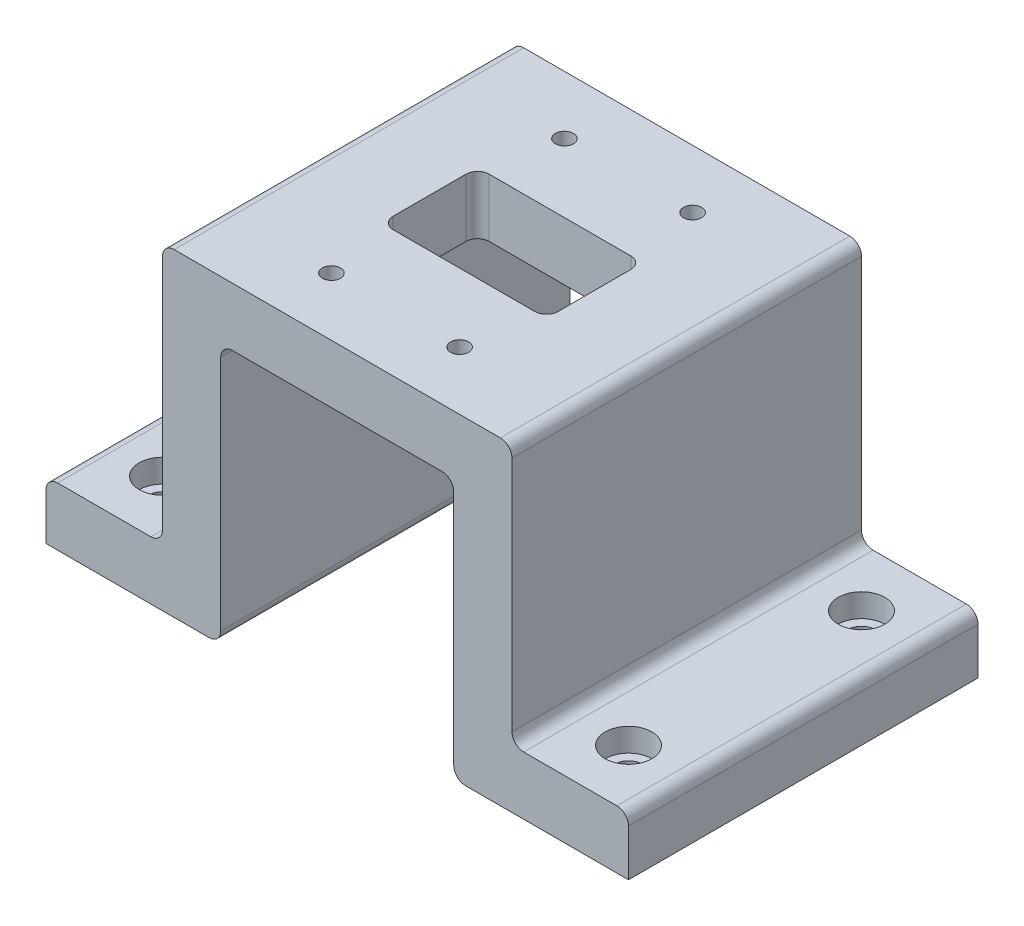
from build123d import *

# Parameters (mm, degrees)
SKETCH2_W                        = 60
SKETCH2_H                        = 60
BOSS_EXTRUDE1_DEPTH              = 10
SKETCH7_W                        = 28.32
SKETCH7_H                        = 16.5
CUT_EXTRUDE2_DEPTH               = 44.588989435
FILLET2_R                        = 2
CBORE_FOR_M2_5_SHCS2_D           = 3.1
CBORE_FOR_M2_5_SHCS2_CBORE_D     = 5.5
CBORE_FOR_M2_5_SHCS2_CBORE_DEPTH = 2.5
MOVE_FACE1_BY                    = 3.5
MOVE_FACE1_2_BY                  = 3.5
MOVE_FACE1_3_BY                  = 3.5
MOVE_FACE1_4_BY                  = 3.5
SKETCH11_W                       = 10
SKETCH11_H                       = 44.7
BOSS_EXTRUDE2_DEPTH              = 60
SKETCH12_W                       = 20
SKETCH12_H                       = 60
BOSS_EXTRUDE3_DEPTH              = 10
CBORE_FOR_M4_SHCS1_D             = 4.8
CBORE_FOR_M4_SHCS1_CBORE_D       = 8
CBORE_FOR_M4_SHCS1_CBORE_DEPTH   = 4
FILLET5_R                        = 2


with BuildPart() as part:
    # Sketch2 → Boss-Extrude1 (new body)
    with BuildSketch(Plane(origin=(0, 0, 0), x_dir=(1, 0, 0), z_dir=(0, 1, 0))):
        Rectangle(SKETCH2_W, SKETCH2_H)
    extrude(amount=BOSS_EXTRUDE1_DEPTH)

    # Sketch7 → Cut-Extrude2 (cut, through all)
    with BuildSketch(Plane(origin=(0, 10, 0), x_dir=(1, 0, 0), z_dir=(0, 1, 0))):
        Rectangle(SKETCH7_W, SKETCH7_H)
    extrude(amount=-CUT_EXTRUDE2_DEPTH, mode=Mode.SUBTRACT)

    # Fillet2
    fillet2_edges = [part.edges().sort_by_distance(p)[0] for p in [
        (-14.16, 5, 8.25),
        (-14.16, 5, -8.25),
        (14.16, 5, -8.25),
        (14.16, 5, 8.25),
    ]]
    fillet(fillet2_edges, radius=FILLET2_R)

    # CBORE for M2.5 SHCS2 (through all)
    with Locations(Plane(origin=(0, 0, 0), x_dir=(-1, 0, 0), z_dir=(0, -1, 0))):
        with Locations((11, -20), (-11, -20), (11, 20), (-11, 20)):
            CounterBoreHole(CBORE_FOR_M2_5_SHCS2_D / 2, CBORE_FOR_M2_5_SHCS2_CBORE_D / 2, CBORE_FOR_M2_5_SHCS2_CBORE_DEPTH)

    # Move Face1: a face moved inward by 3.5
    extrude(part.faces().sort_by_distance((11, 2.5, -17.8))[0], amount=MOVE_FACE1_BY, dir=(0, 1, 0), mode=Mode.SUBTRACT)

    # Move Face1 2: a face moved inward by 3.5
    extrude(part.faces().sort_by_distance((-11, 2.5, -17.8))[0], amount=MOVE_FACE1_2_BY, dir=(0, 1, 0), mode=Mode.SUBTRACT)

    # Move Face1 3: a face moved inward by 3.5
    extrude(part.faces().sort_by_distance((11, 2.5, 22.2))[0], amount=MOVE_FACE1_3_BY, dir=(0, 1, 0), mode=Mode.SUBTRACT)

    # Move Face1 4: a face moved inward by 3.5
    extrude(part.faces().sort_by_distance((-11, 2.5, 22.2))[0], amount=MOVE_FACE1_4_BY, dir=(0, 1, 0), mode=Mode.SUBTRACT)

    # Sketch11 → Boss-Extrude2 (add)
    with BuildSketch(Plane(origin=(0, 0, -30), x_dir=(-1, 0, 0), z_dir=(0, 0, -1))):
        with Locations((-25, -22.35)):
            Rectangle(SKETCH11_W, SKETCH11_H)
    boss_extrude2 = extrude(amount=-BOSS_EXTRUDE2_DEPTH)

    # Sketch12 → Boss-Extrude3 (add)
    with BuildSketch(Plane.XZ.offset(44.7)):
        with Locations((40, 0)):
            Rectangle(SKETCH12_W, SKETCH12_H)
    boss_extrude3 = extrude(amount=-BOSS_EXTRUDE3_DEPTH)

    # CBORE for M4 SHCS1 (through all)
    with Locations(Plane(origin=(0, -34.7, 0), x_dir=(1, 0, 0), z_dir=(0, 1, 0))):
        with Locations((40, 20), (40, -20)):
            cbore_for_m4_shcs1 = CounterBoreHole(CBORE_FOR_M4_SHCS1_D / 2, CBORE_FOR_M4_SHCS1_CBORE_D / 2, CBORE_FOR_M4_SHCS1_CBORE_DEPTH)

    # Mirror1: Boss-Extrude2, Boss-Extrude3, CBORE for M4 SHCS1 across plane
    add(boss_extrude2.mirror(Plane(origin=(0, 0, 0), x_dir=(0, 0, 1), z_dir=(1, 0, 0))))
    add(boss_extrude3.mirror(Plane(origin=(0, 0, 0), x_dir=(0, 0, 1), z_dir=(1, 0, 0))))
    add(cbore_for_m4_shcs1.mirror(Plane(origin=(0, 0, 0), x_dir=(0, 0, 1), z_dir=(1, 0, 0))), mode=Mode.SUBTRACT)

    # Fillet5
    fillet5_edges = [part.edges().sort_by_distance(p)[0] for p in [
        (50, -34.7, 0),
        (30, -34.7, 0),
        (30, 10, 0),
        (-20, 0, 0),
        (-20, -44.7, 0),
        (-30, -34.7, 0),
        (-50, -34.7, 0),
        (-30, 10, 0),
        (20, 0, 0),
        (20, -44.7, 0),
    ]]
    fillet(fillet5_edges, radius=FILLET5_R)


solid = part.part
